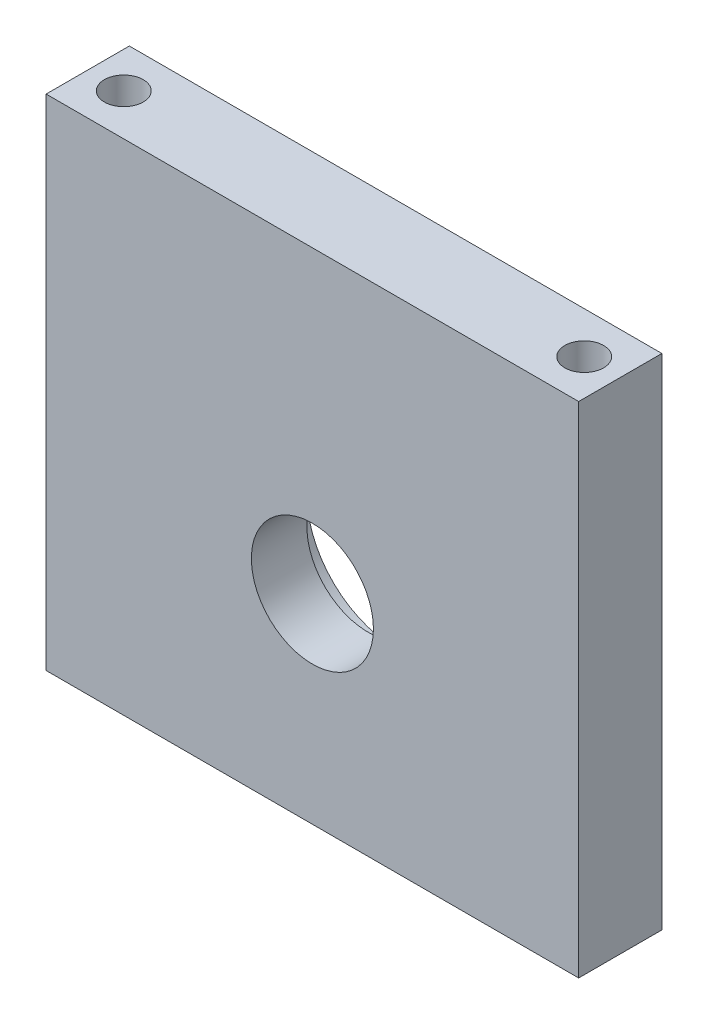
from build123d import *

# Parameters (mm, degrees)
ESQUISSE1_W             = 48
ESQUISSE1_H             = 45
BOSS_EXTRU_1_DEPTH      = 7.5
ESQUISSE2_R             = 1.75
ENL_V_MAT_EXTRU_1_DEPTH = 7
ESQUISSE3_R             = 1.75
ENL_V_MAT_EXTRU_2_DEPTH = 7
ESQUISSE5_R             = 5.5
ENL_V_MAT_EXTRU_3_DEPTH = 5
ESQUISSE4_R             = 8
ENL_V_MAT_EXTRU_4_DEPTH = 2.5


with BuildPart() as part:
    # Esquisse1 → Boss.-Extru.1 (new body)
    with BuildSketch(Plane.XY):
        Rectangle(ESQUISSE1_W, ESQUISSE1_H)
    extrude(amount=BOSS_EXTRU_1_DEPTH)

    # Esquisse2 → Enlèv. mat.-Extru.1 (cut)
    with BuildSketch(Plane.XZ.offset(22.5)):
        with Locations((-20.75, 3.75)):
            Circle(ESQUISSE2_R)
        with Locations((20.75, 3.75)):
            Circle(ESQUISSE2_R)
    extrude(amount=-ENL_V_MAT_EXTRU_1_DEPTH, mode=Mode.SUBTRACT)

    # Esquisse3 → Enlèv. mat.-Extru.2 (cut)
    with BuildSketch(Plane(origin=(0, 22.5, 0), x_dir=(1, 0, 0), z_dir=(0, 1, 0))):
        with Locations((-20.75, -3.75)):
            Circle(ESQUISSE3_R)
        with Locations((20.75, -3.75)):
            Circle(ESQUISSE3_R)
    extrude(amount=-ENL_V_MAT_EXTRU_2_DEPTH, mode=Mode.SUBTRACT)

    # Esquisse5 → Enlèv. mat.-Extru.3 (cut)
    with BuildSketch(Plane.XY.offset(7.5)):
        with Locations((0, -4.5)):
            Circle(ESQUISSE5_R)
    extrude(amount=-ENL_V_MAT_EXTRU_3_DEPTH, mode=Mode.SUBTRACT)

    # Esquisse4 → Enlèv. mat.-Extru.4 (cut)
    with BuildSketch(Plane(origin=(0, 0, 0), x_dir=(-1, 0, 0), z_dir=(0, 0, -1))):
        with Locations((0, -4.5)):
            Circle(ESQUISSE4_R)
    extrude(amount=-ENL_V_MAT_EXTRU_4_DEPTH, mode=Mode.SUBTRACT)


solid = part.part
